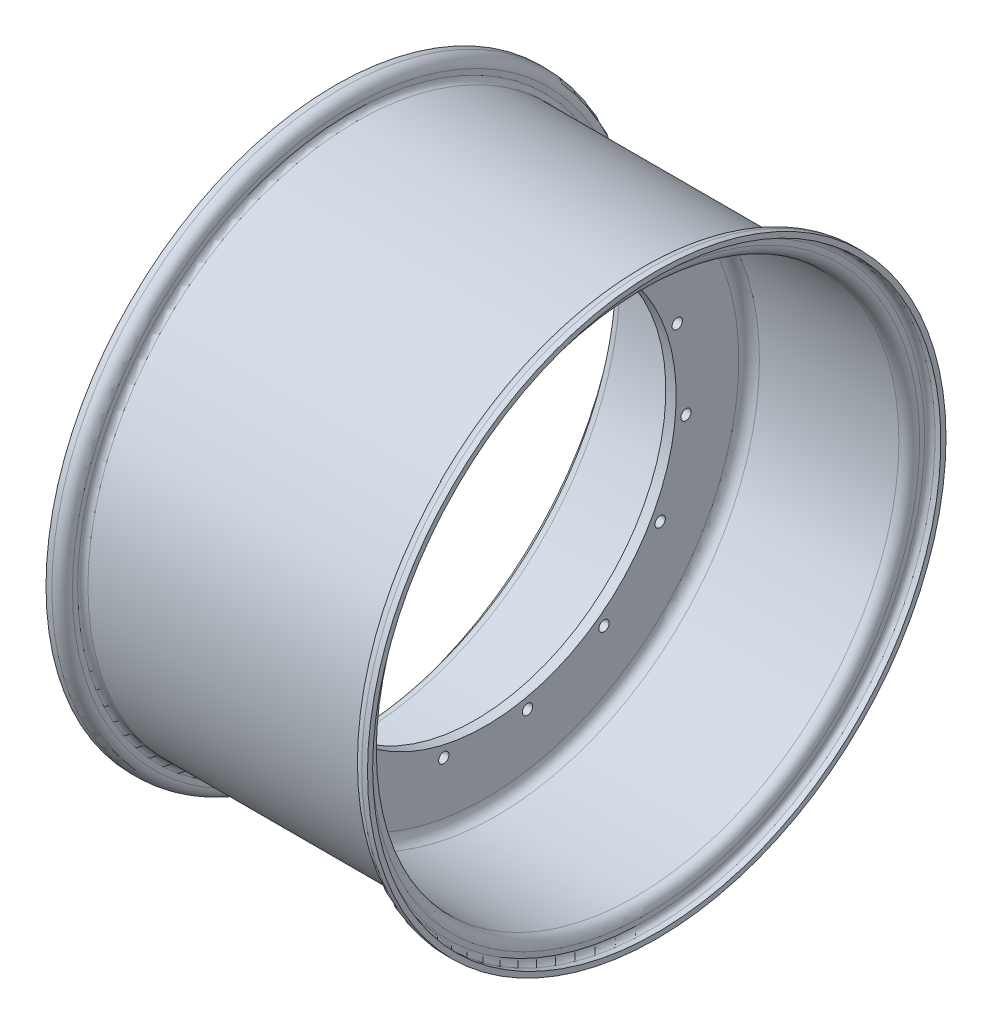
from build123d import *

# Parameters (mm, degrees)
SKETCH2_R          = 3.175
CUT_EXTRUDE1_DEPTH = 112.506
CIRPATTERN1_COUNT  = 15
FILLET1_R          = 6.35


with BuildPart() as part:
    # Sketch1 → Revolve1 (revolve)
    with BuildSketch(Plane.XY):
        with BuildLine():
            Line((0, 165.1), (95.25, 165.1))
            ThreePointArc((95.25, 165.1), (97.49506403, 166.02993597), (98.425, 168.275))
            Line((98.425, 168.275), (98.425, 171.45))
            ThreePointArc((98.425, 171.45), (100.284871939, 175.940128061), (104.775, 177.8))
            Line((104.775, 177.8), (108.331, 177.8))
            Line((108.331, 177.8), (108.331, 174.625))
            Line((108.331, 174.625), (104.775, 174.625))
            ThreePointArc((104.775, 174.625), (102.52993597, 173.69506403), (101.6, 171.45))
            Line((101.6, 171.45), (101.6, 168.275))
            ThreePointArc((101.6, 168.275), (99.740128061, 163.784871939), (95.25, 161.925))
            Line((95.25, 161.925), (3.175, 161.925))
            Line((3.175, 161.925), (3.175, 117.094))
            Line((3.175, 117.094), (-3.175, 117.094))
            Line((-3.175, 117.094), (-3.175, 161.925))
            Line((-3.175, 161.925), (-76.2, 161.925))
            ThreePointArc((-76.2, 161.925), (-80.690128061, 163.784871939), (-82.55, 168.275))
            Line((-82.55, 168.275), (-82.55, 171.45))
            ThreePointArc((-82.55, 171.45), (-83.47993597, 173.69506403), (-85.725, 174.625))
            Line((-85.725, 174.625), (-89.281, 174.625))
            Line((-89.281, 174.625), (-89.281, 177.8))
            Line((-89.281, 177.8), (-85.725, 177.8))
            ThreePointArc((-85.725, 177.8), (-81.234871939, 175.940128061), (-79.375, 171.45))
            Line((-79.375, 171.45), (-79.375, 168.275))
            ThreePointArc((-79.375, 168.275), (-78.44506403, 166.02993597), (-76.2, 165.1))
            Line((-76.2, 165.1), (0, 165.1))
        make_face()
    revolve(axis=Axis((-87.037910478, 0, 0), (1, 0, 0)))

    # Sketch2 → Cut-Extrude1 (cut, through all)
    with BuildSketch(Plane.ZY.offset(3.175)):
        with Locations((0, 123.825)):
            Circle(SKETCH2_R)
    cut_extrude1 = extrude(amount=-CUT_EXTRUDE1_DEPTH, mode=Mode.SUBTRACT)

    # CirPattern1: Cut-Extrude1 ×15 about axis
    cirpattern1_axis = Axis((0, 0, 0), (1, 0, 0))
    for i in range(1, CIRPATTERN1_COUNT):
        add(cut_extrude1.rotate(cirpattern1_axis, i * 360 / CIRPATTERN1_COUNT), mode=Mode.SUBTRACT)

    # Fillet1
    fillet1_edges = [part.edges().sort_by_distance(p)[0] for p in [
        (-3.175, -161.925, 0),
        (3.175, -161.925, 0),
    ]]
    fillet(fillet1_edges, radius=FILLET1_R)


solid = part.part
